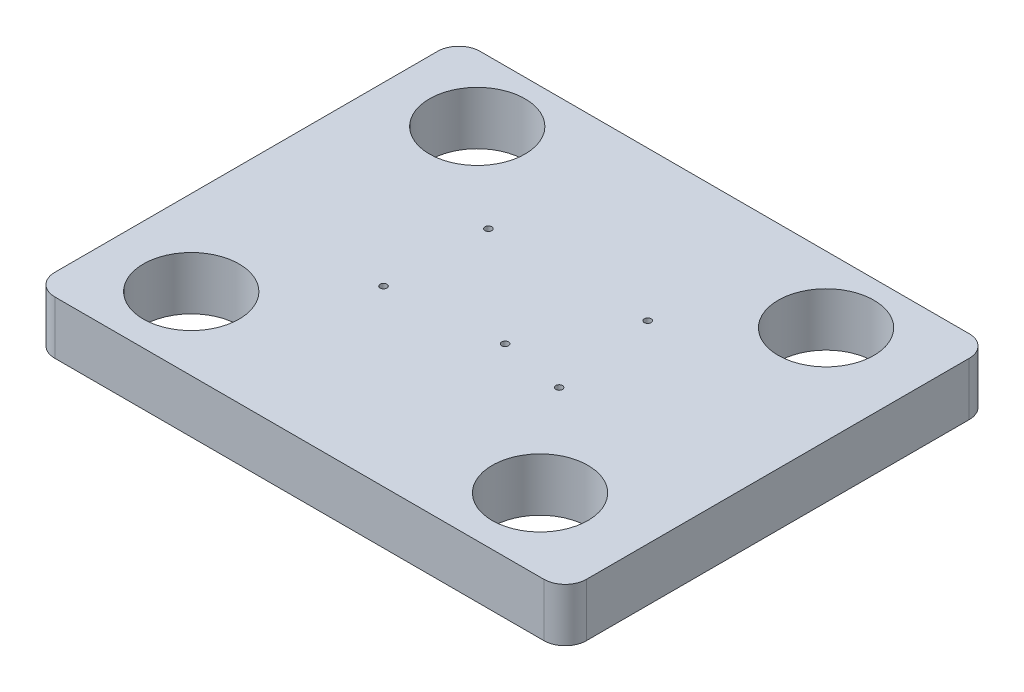
from build123d import *

# Parameters (mm, degrees)
SKETCH2_W           = 250
SKETCH2_H           = 200
BOSS_EXTRUDE1_DEPTH = 25
FILLET1_R           = 10
FILLET2_R           = 10
FILLET3_R           = 10
FILLET4_R           = 10
SKETCH3_R           = 1.6
CUT_EXTRUDE1_DEPTH  = 26
SKETCH4_R           = 22.5
CUT_EXTRUDE2_DEPTH  = 26


with BuildPart() as part:
    # Sketch2 → Boss-Extrude1 (new body)
    with BuildSketch(Plane(origin=(0, 0, 0), x_dir=(1, 0, 0), z_dir=(0, 1, 0))):
        with Locations((125, 100)):
            Rectangle(SKETCH2_W, SKETCH2_H)
    extrude(amount=BOSS_EXTRUDE1_DEPTH)

    # Fillet1
    fillet1_edges = [part.edges().sort_by_distance(p)[0] for p in [
        (0, 12.5, 0),
    ]]
    fillet(fillet1_edges, radius=FILLET1_R)

    # Fillet2
    fillet2_edges = [part.edges().sort_by_distance(p)[0] for p in [
        (250, 12.5, 0),
    ]]
    fillet(fillet2_edges, radius=FILLET2_R)

    # Fillet3
    fillet3_edges = [part.edges().sort_by_distance(p)[0] for p in [
        (250, 12.5, -200),
    ]]
    fillet(fillet3_edges, radius=FILLET3_R)

    # Fillet4
    fillet4_edges = [part.edges().sort_by_distance(p)[0] for p in [
        (0, 12.5, -200),
    ]]
    fillet(fillet4_edges, radius=FILLET4_R)

    # Sketch3 → Cut-Extrude1 (cut, through all)
    with BuildSketch(Plane(origin=(0, 25, 0), x_dir=(1, 0, 0), z_dir=(0, 1, 0))):
        with Locations((84.183925072, 129.712061316)):
            Circle(SKETCH3_R)
        with Locations((82.913925072, 81.676079735)):
            Circle(SKETCH3_R)
        with Locations((165.463925072, 81.676079735)):
            Circle(SKETCH3_R)
        with Locations((159.113925072, 129.712061316)):
            Circle(SKETCH3_R)
        with Locations((134.983925072, 86.756079735)):
            Circle(SKETCH3_R)
    extrude(amount=-CUT_EXTRUDE1_DEPTH, mode=Mode.SUBTRACT)

    # Sketch4 → Cut-Extrude2 (cut, through all)
    with BuildSketch(Plane(origin=(0, 25, 0), x_dir=(1, 0, 0), z_dir=(0, 1, 0))):
        with Locations((203.930975459, 168.75038786)):
            Circle(SKETCH4_R)
        with Locations((203.930975459, 34.26608254)):
            Circle(SKETCH4_R)
        with Locations((39.910397475, 34.26608254)):
            Circle(SKETCH4_R)
        with Locations((39.910397475, 168.75038786)):
            Circle(SKETCH4_R)
    extrude(amount=-CUT_EXTRUDE2_DEPTH, mode=Mode.SUBTRACT)


solid = part.part
